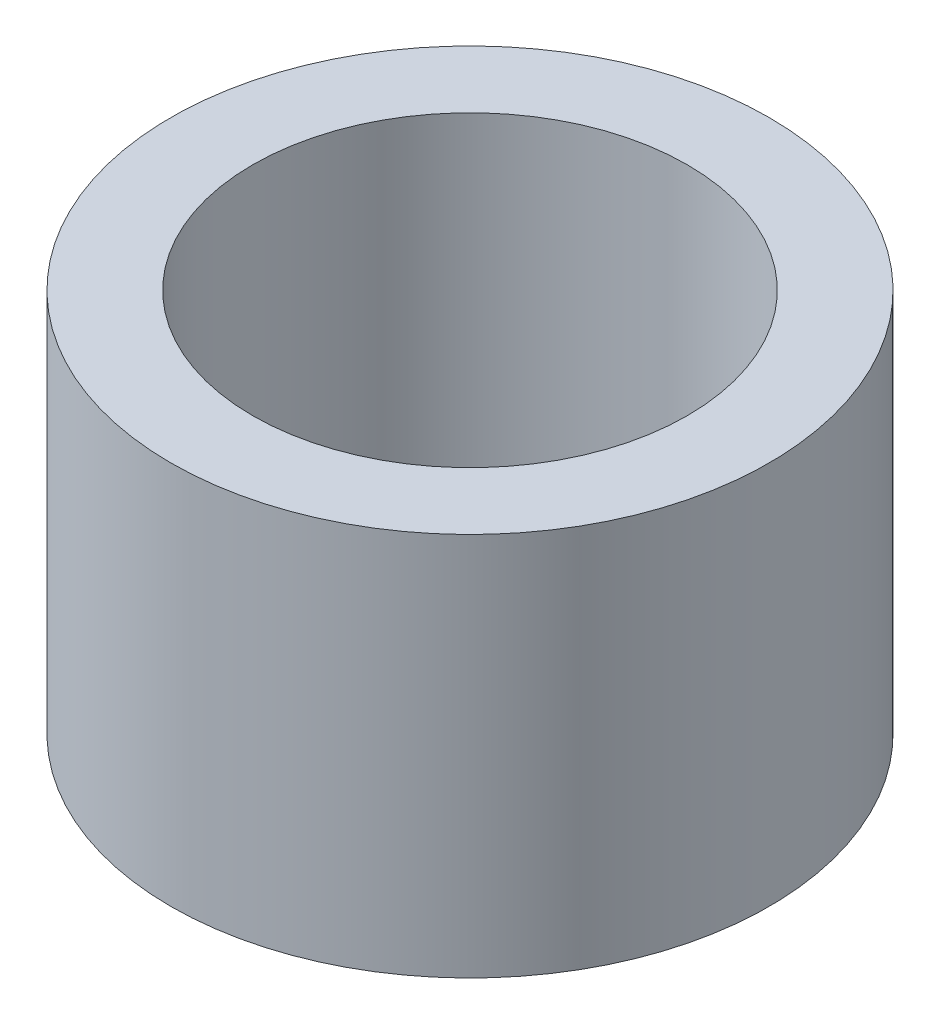
from build123d import *

# Parameters (mm, degrees)
SKETCH1_R           = 6.215
SKETCH1_R_2         = 4.515
BOSS_EXTRUDE3_DEPTH = 7.98


with BuildPart() as part:
    # Sketch1 → Boss-Extrude3 (new body)
    with BuildSketch(Plane(origin=(0, 0, 0), x_dir=(1, 0, 0), z_dir=(0, 1, 0))):
        Circle(SKETCH1_R)
        Circle(SKETCH1_R_2, mode=Mode.SUBTRACT)
    extrude(amount=BOSS_EXTRUDE3_DEPTH)


solid = part.part
